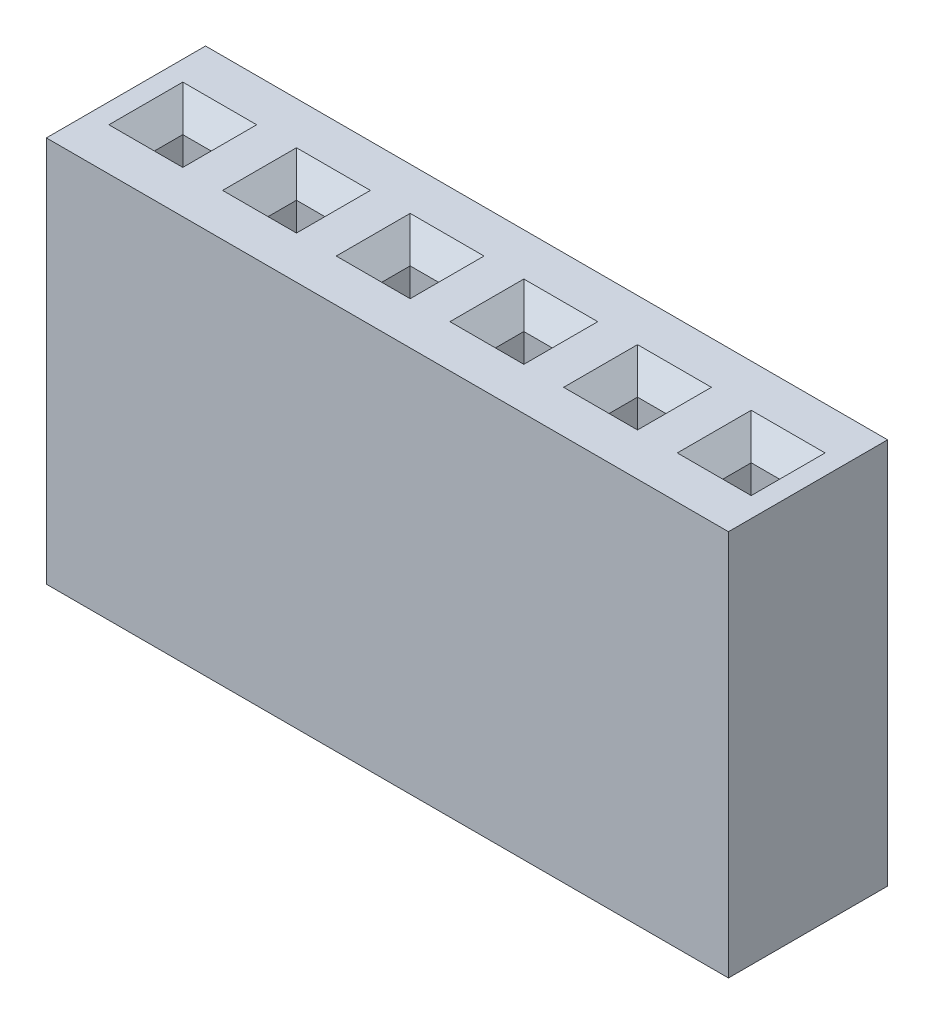
from build123d import *

# Parameters (mm, degrees)
SKETCH1_W                  = 15.24
SKETCH1_H                  = 3.556
BOSS_EXTRUDE1_DEPTH        = 8.636
SKETCH2_W                  = 0.635
SKETCH2_H                  = 0.635
CUT_EXTRUDE1_DEPTH         = 6.35
CHAMFER1_SIZE              = 0.508
LPATTERN1_COUNT            = 6
LPATTERN1_PITCH            = 2.54
CHAMFER1_OF_LPATTERN1_SIZE = 0.508


with BuildPart() as part:
    # Sketch1 → Boss-Extrude1 (new body)
    with BuildSketch(Plane(origin=(0, 0, 0), x_dir=(1, 0, 0), z_dir=(0, 1, 0))):
        with Locations((7.62, 1.778)):
            Rectangle(SKETCH1_W, SKETCH1_H)
    extrude(amount=BOSS_EXTRUDE1_DEPTH)

    # Sketch2 → Cut-Extrude1 (cut)
    with BuildSketch(Plane(origin=(0, 8.636, 0), x_dir=(1, 0, 0), z_dir=(0, 1, 0))):
        with Locations((1.27, 1.778)):
            Rectangle(SKETCH2_W, SKETCH2_H)
    cut_extrude1 = extrude(amount=-CUT_EXTRUDE1_DEPTH, mode=Mode.SUBTRACT)

    # Chamfer1
    chamfer1_edges = [part.edges().sort_by_distance(p)[0] for p in [
        (1.5875, 8.636, -1.778),
        (1.27, 8.636, -2.0955),
        (0.9525, 8.636, -1.778),
        (1.27, 8.636, -1.4605),
    ]]
    chamfer(chamfer1_edges, length=CHAMFER1_SIZE)

    # LPattern1: Cut-Extrude1 ×6
    with Locations(*[(i * LPATTERN1_PITCH, 0, 0) for i in range(1, LPATTERN1_COUNT)]):
        add(cut_extrude1, mode=Mode.SUBTRACT)

    # Chamfer1 of LPattern1
    chamfer1_of_lpattern1_edges = [part.edges().sort_by_distance(p)[0] for p in [
        (4.1275, 8.636, -1.778),
        (3.81, 8.636, -2.0955),
        (3.4925, 8.636, -1.778),
        (3.81, 8.636, -1.4605),
        (6.6675, 8.636, -1.778),
        (6.35, 8.636, -2.0955),
        (6.0325, 8.636, -1.778),
        (6.35, 8.636, -1.4605),
        (9.2075, 8.636, -1.778),
        (8.89, 8.636, -2.0955),
        (8.5725, 8.636, -1.778),
        (8.89, 8.636, -1.4605),
        (11.7475, 8.636, -1.778),
        (11.43, 8.636, -2.0955),
        (11.1125, 8.636, -1.778),
        (11.43, 8.636, -1.4605),
        (14.2875, 8.636, -1.778),
        (13.97, 8.636, -2.0955),
        (13.6525, 8.636, -1.778),
        (13.97, 8.636, -1.4605),
    ]]
    chamfer(chamfer1_of_lpattern1_edges, length=CHAMFER1_OF_LPATTERN1_SIZE)


solid = part.part
